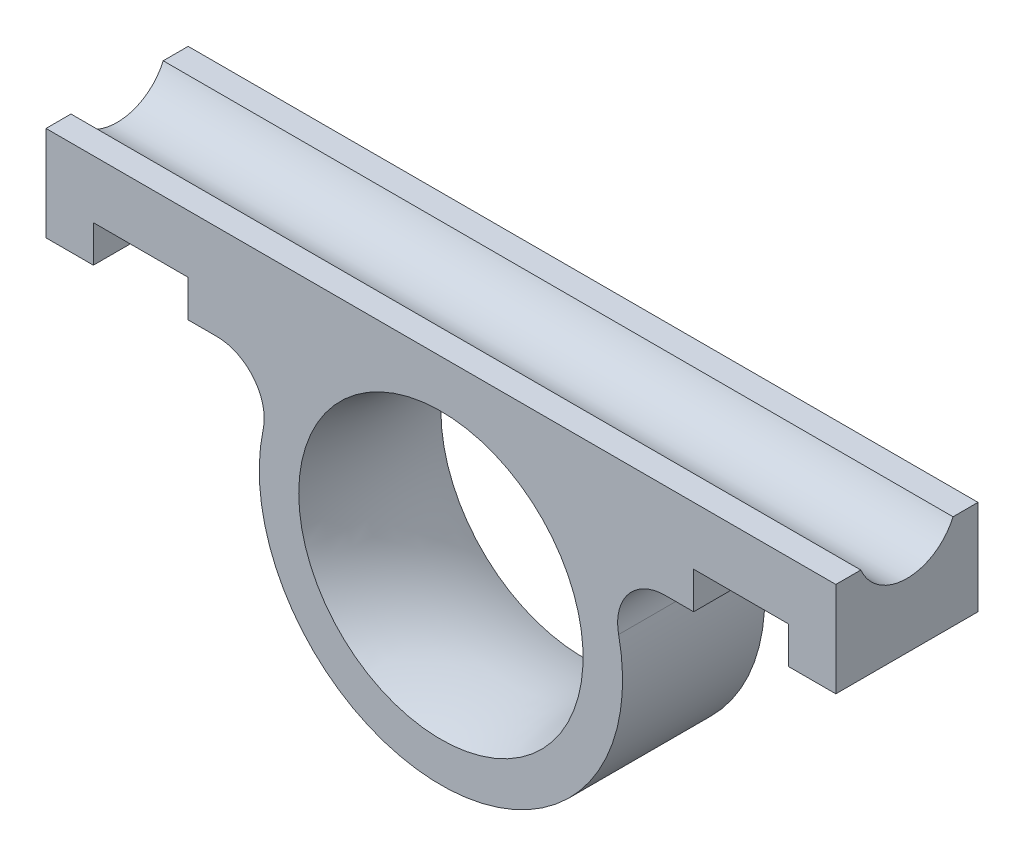
from build123d import *

# Parameters (mm, degrees)
SKETCH2_R           = 8.25
BOSS_EXTRUDE1_DEPTH = 9
SKETCH3_R           = 3.175
CUT_EXTRUDE1_DEPTH  = 51
SKETCH4_OUTSIDE_W   = 22.196
SKETCH4_OUTSIDE_H   = 36.696
SKETCH4_OUTSIDE_R   = 8.25
CUT_EXTRUDE2_DEPTH  = 6
CUT_EXTRUDE3_DEPTH  = 6


with BuildPart() as part:
    # Sketch2 → Boss-Extrude1 (new body)
    with BuildSketch(Plane.XY):
        with BuildLine():
            Line((-25, 12), (25, 12))
            Line((25, 12), (25, 6))
            Line((25, 6), (22, 6))
            Line((22, 6), (22, 7))
            Line((22, 7), (16, 7))
            Line((16, 7), (16, 6))
            Line((16, 6), (14.186260959, 6))
            ThreePointArc((14.186260959, 6), (11.855802961, 4.88917059), (11.251172485, 2.379310345))
            ThreePointArc((11.251172485, 2.379310345), (0, -11.5), (-11.251172485, 2.379310345))
            ThreePointArc((-11.251172485, 2.379310345), (-11.855802961, 4.88917059), (-14.186260959, 6))
            Line((-14.186260959, 6), (-16, 6))
            Line((-16, 6), (-16, 7))
            Line((-16, 7), (-22, 7))
            Line((-22, 7), (-22, 6))
            Line((-22, 6), (-25, 6))
            Line((-25, 6), (-25, 12))
        make_face()
        Circle(SKETCH2_R, mode=Mode.SUBTRACT)
    extrude(amount=BOSS_EXTRUDE1_DEPTH)

    # Sketch3 → Cut-Extrude1 (cut, through all)
    with BuildSketch(Plane(origin=(25, 0, 0), x_dir=(0, 0, -1), z_dir=(1, 0, 0))):
        with Locations((-4.5, 13.25)):
            Circle(SKETCH3_R)
    extrude(amount=-CUT_EXTRUDE1_DEPTH, mode=Mode.SUBTRACT)

    # Sketch4 outside → Cut-Extrude2 (cut)
    with BuildSketch(Plane(origin=(-22, 0, 0), x_dir=(0, 0, -1), z_dir=(1, 0, 0))):
        with Locations((-4.5, 0.25)):
            Rectangle(SKETCH4_OUTSIDE_W, SKETCH4_OUTSIDE_H)
        with Locations((-4.5, 15.25)):
            Circle(SKETCH4_OUTSIDE_R, mode=Mode.SUBTRACT)
    extrude(amount=CUT_EXTRUDE2_DEPTH, mode=Mode.SUBTRACT)

    # Sketch5 → Cut-Extrude3 (cut)
    with BuildSketch(Plane.ZY.offset(-16)):
        with BuildLine():
            Line((0, 8.335341657), (0, 6))
            Line((0, 6), (9, 6))
            Line((9, 6), (9, 8.335341657))
            ThreePointArc((9, 8.335341657), (4.5, 7), (0, 8.335341657))
        make_face()
    extrude(amount=-CUT_EXTRUDE3_DEPTH, mode=Mode.SUBTRACT)

    # Sketch6 → Cut-Revolve1 (revolve, cut)
    with BuildSketch(Plane(origin=(0, 0, 0), x_dir=(0, 0, -1), z_dir=(1, 0, 0)), mode=Mode.PRIVATE) as cut_revolve1_sk:
        with BuildLine():
            Line((-9, 9), (-9, 0))
            Line((-9, 0), (0, 0))
            Line((0, 0), (0, 9))
            ThreePointArc((0, 9), (-4.5, 8.25), (-9, 9))
        make_face()
    revolve(cut_revolve1_sk.sketch.rotate(Axis((0, 0, 9), (0, 0, 1)), 90), axis=Axis((0, 0, 9), (0, 0, 1)), mode=Mode.SUBTRACT)  # turned: the seam where the file's is


solid = part.part
